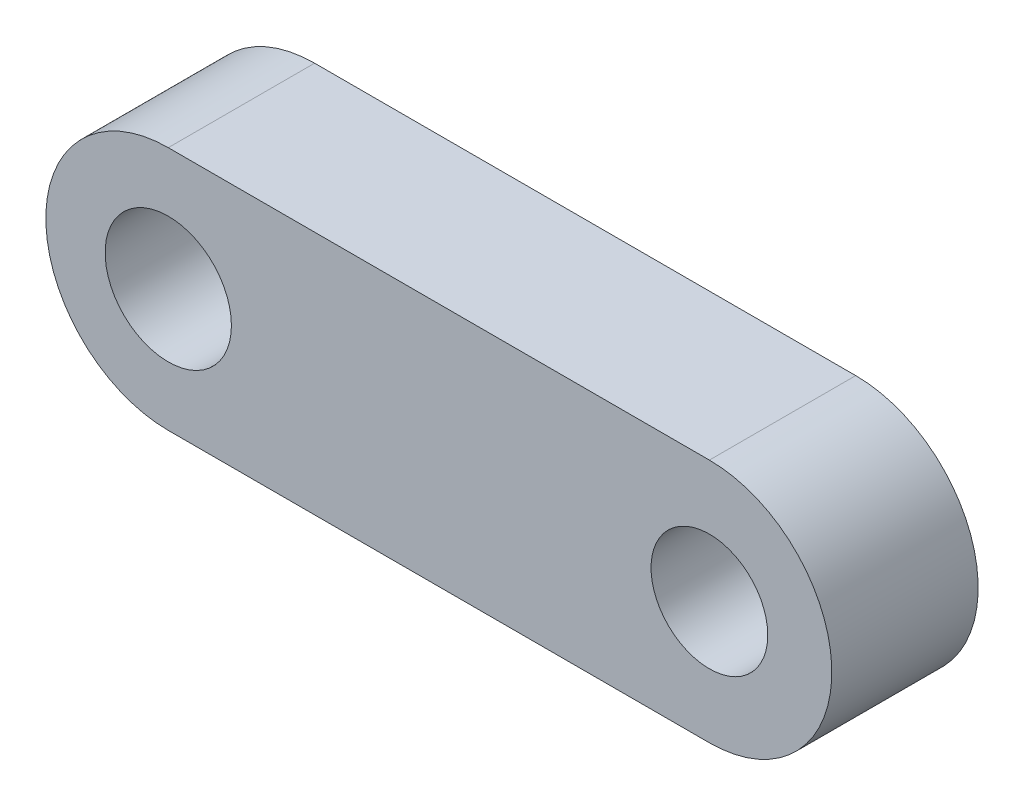
from build123d import *

# Parameters (mm, degrees)
SKETCH1_R           = 14.238251154
SKETCH1_R_2         = 13.158970378
BOSS_EXTRUDE1_DEPTH = 33


with BuildPart() as part:
    # Sketch1 → Boss-Extrude1 (new body)
    with BuildSketch(Plane.XY):
        with BuildLine():
            Line((-61.01754962, 27.610495658), (61.01754962, 27.610495658))
            ThreePointArc((61.01754962, 27.610495658), (88.628045278, 0), (61.01754962, -27.610495658))
            Line((61.01754962, -27.610495658), (-61.01754962, -27.610495658))
            ThreePointArc((-61.01754962, -27.610495658), (-88.628045278, 0), (-61.01754962, 27.610495658))
        make_face()
        with Locations((-61.01754962, 0)):
            Circle(SKETCH1_R, mode=Mode.SUBTRACT)
        with Locations((61.01754962, 0)):
            Circle(SKETCH1_R_2, mode=Mode.SUBTRACT)
    extrude(amount=BOSS_EXTRUDE1_DEPTH)


solid = part.part
